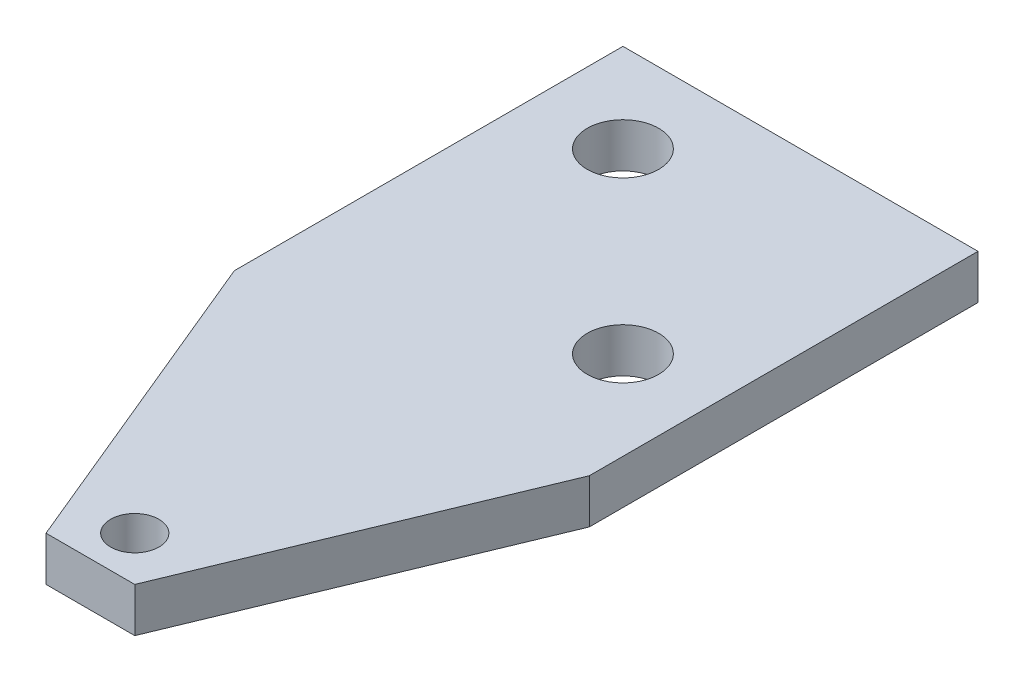
from build123d import *

# Parameters (mm, degrees)
BOSS_EXTRUDE1_DEPTH    = 3.175
F_10_CLEARANCE_HOLE1_D = 5.1054
F_8_32_TAPPED_HOLE1_D  = 3.4544


with BuildPart() as part:
    # Sketch1 → Boss-Extrude1 (new body)
    with BuildSketch(Plane(origin=(0, 0, 0), x_dir=(1, 0, 0), z_dir=(0, 1, 0))):
        Polygon((-12.7, -12.7), (-12.7, -15.104615818), (-3.175, -38.1), (3.175, -38.1), (12.7, -15.104615818), (12.7, -12.7), (12.7, 12.7), (-12.7, 12.7), align=None)
    extrude(amount=BOSS_EXTRUDE1_DEPTH)

    # #10 Clearance Hole1 (through all)
    with Locations(Plane(origin=(0, 3.175, 0), x_dir=(1, 0, 0), z_dir=(0, 1, 0))):
        with Locations((-6.35, 6.35), (6.35, -6.35)):
            Hole(F_10_CLEARANCE_HOLE1_D / 2)

    # #8-32 Tapped Hole1 (through all)
    with Locations(Plane(origin=(0, 3.175, 0), x_dir=(1, 0, 0), z_dir=(0, 1, 0))):
        with Locations((0, -34.925)):
            Hole(F_8_32_TAPPED_HOLE1_D / 2)


solid = part.part
